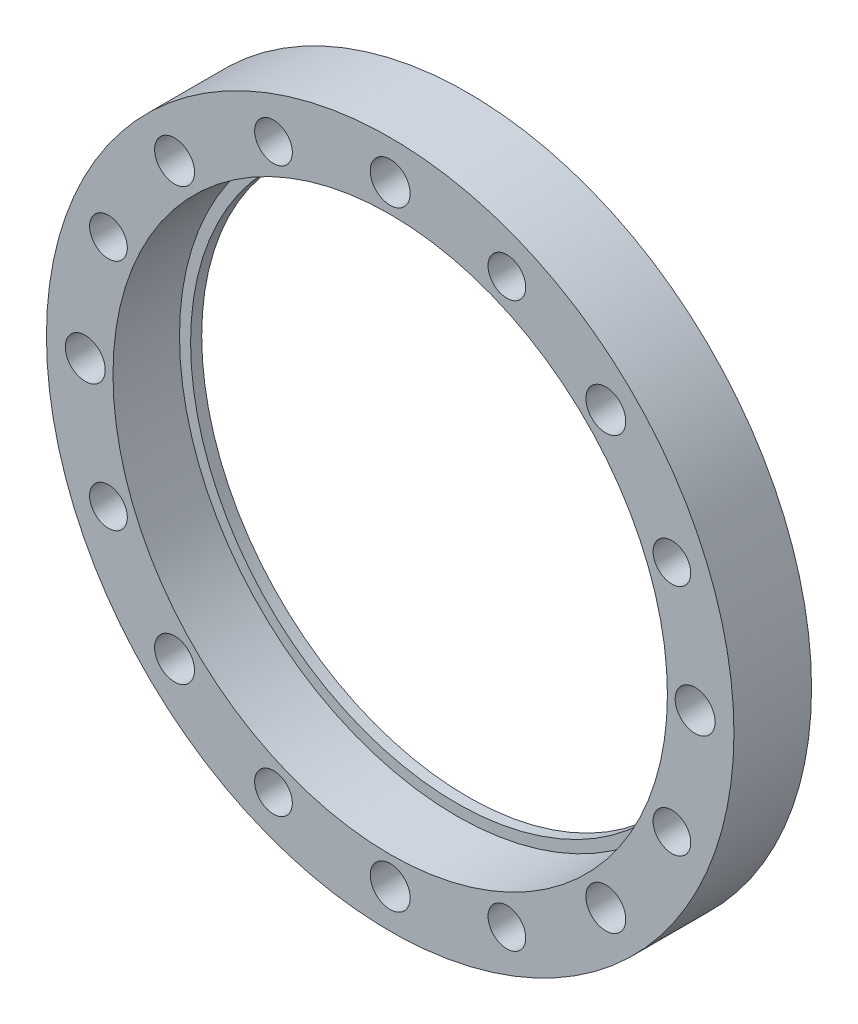
from build123d import *

# Parameters (mm, degrees)
SKETCH_1_R                   = 31
EXTRUDE_1_DEPTH              = 6
SKETCH_3_R                   = 25
CUT_EXTRUDE_1_DEPTH          = 7
SKETCH_5_R                   = 31
SKETCH_5_R_2                 = 24
EXTRUDE_2_DEPTH              = 1
HOLE_WIZARD_M3_1_D           = 3.6
HOLE_WIZARD_M3_1_CSINK_D     = 6.3
HOLE_WIZARD_M3_1_CSINK_ANGLE = 90
PATTERN_CIRCULAR_1_COUNT     = 8
HOLE_WIZARD_M3_1_2_D         = 3.4
PATTERN_CIRCULAR_2_COUNT     = 8


with BuildPart() as part:
    # ｽｹｯﾁ1 → ﾎﾞｽ - 押し出し1 (new body)
    with BuildSketch(Plane.XY):
        Circle(SKETCH_1_R)
    extrude(amount=EXTRUDE_1_DEPTH)

    # ｽｹｯﾁ3 → ｶｯﾄ - 押し出し1 (cut, through all)
    with BuildSketch(Plane(origin=(0, 0, 0), x_dir=(-1, 0, 0), z_dir=(0, 0, -1))):
        Circle(SKETCH_3_R)
    extrude(amount=-CUT_EXTRUDE_1_DEPTH, mode=Mode.SUBTRACT)

    # ｽｹｯﾁ5 → ﾎﾞｽ - 押し出し2 (add)
    with BuildSketch(Plane(origin=(0, 0, 0), x_dir=(-1, 0, 0), z_dir=(0, 0, -1))):
        Circle(SKETCH_5_R)
        Circle(SKETCH_5_R_2, mode=Mode.SUBTRACT)
    extrude(amount=EXTRUDE_2_DEPTH)

    # Hole Wizard M3 _1 (through all)
    with Locations(Plane(origin=(0, 0, -1), x_dir=(-1, 0, 0), z_dir=(0, 0, -1))):
        with Locations((0, 27.5)):
            hole_wizard_m3_1 = CounterSinkHole(HOLE_WIZARD_M3_1_D / 2, HOLE_WIZARD_M3_1_CSINK_D / 2, counter_sink_angle=HOLE_WIZARD_M3_1_CSINK_ANGLE)

    # 円形ﾊﾟﾀｰﾝ1: Hole Wizard M3 _1 ×8 about axis
    pattern_circular_1_axis = Axis((0, 0, 0), (0, 0, 1))
    for i in range(1, PATTERN_CIRCULAR_1_COUNT):
        add(hole_wizard_m3_1.rotate(pattern_circular_1_axis, i * 360 / PATTERN_CIRCULAR_1_COUNT), mode=Mode.SUBTRACT)

    # Hole Wizard M3 _1 2 (through all)
    with Locations(Plane(origin=(0, 0, -1), x_dir=(-1, 0, 0), z_dir=(0, 0, -1))):
        with Locations((-10.52379439, 25.406687144)):
            hole_wizard_m3_1_2 = Hole(HOLE_WIZARD_M3_1_2_D / 2)

    # 円形ﾊﾟﾀｰﾝ2: Hole Wizard M3 _1 2 ×8 about axis
    pattern_circular_2_axis = Axis((0, 0, 0), (0, 0, 1))
    for i in range(1, PATTERN_CIRCULAR_2_COUNT):
        add(hole_wizard_m3_1_2.rotate(pattern_circular_2_axis, i * 360 / PATTERN_CIRCULAR_2_COUNT), mode=Mode.SUBTRACT)


solid = part.part
